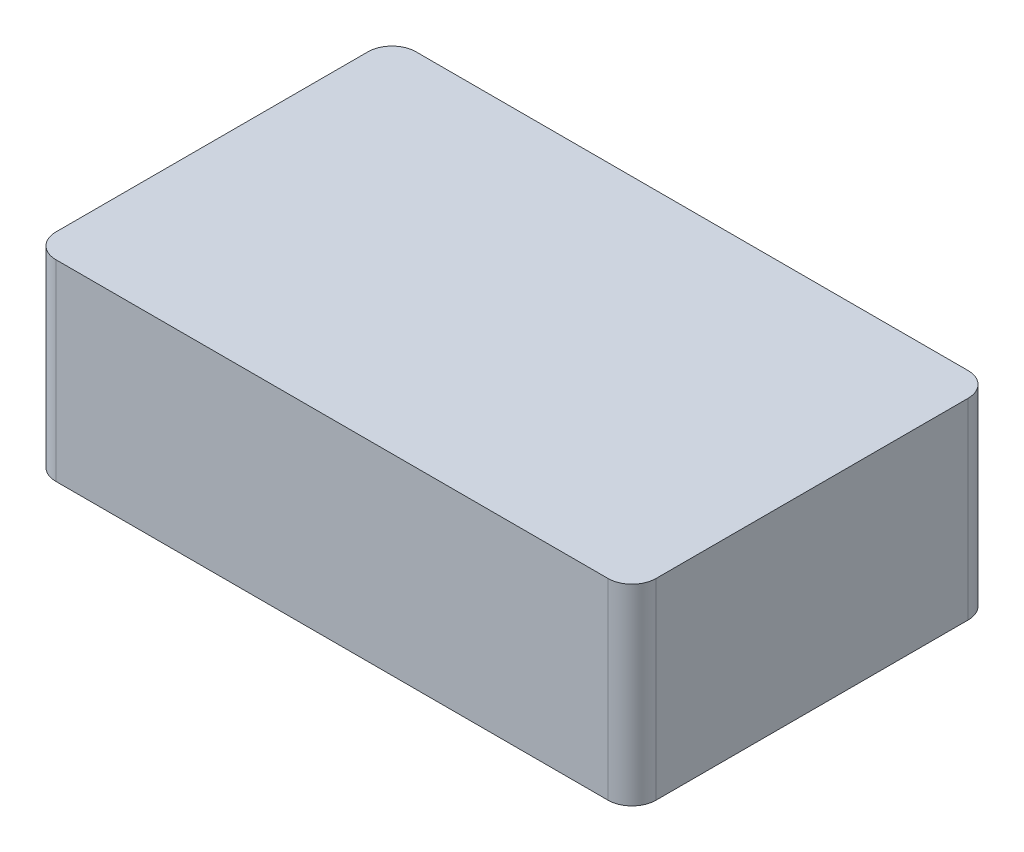
from build123d import *

# Parameters (mm, degrees)
BOSS_EXTRUDE1_DEPTH = 80


with BuildPart() as part:
    # Sketch1 → Boss-Extrude1 (new body)
    with BuildSketch(Plane(origin=(0, 0, 0), x_dir=(1, 0, 0), z_dir=(0, 1, 0))):
        with BuildLine():
            Line((100, 90.402295225), (-130, 90.402295225))
            ThreePointArc((-130, 90.402295225), (-137.071067812, 87.473363037), (-140, 80.402295225))
            Line((-140, 80.402295225), (-140, -49.597704775))
            ThreePointArc((-140, -49.597704775), (-137.071067812, -56.668772587), (-130, -59.597704775))
            Line((-130, -59.597704775), (100, -59.597704775))
            ThreePointArc((100, -59.597704775), (107.071067812, -56.668772587), (110, -49.597704775))
            Line((110, -49.597704775), (110, 80.402295225))
            ThreePointArc((110, 80.402295225), (107.071067812, 87.473363037), (100, 90.402295225))
        make_face()
    extrude(amount=BOSS_EXTRUDE1_DEPTH)


solid = part.part
